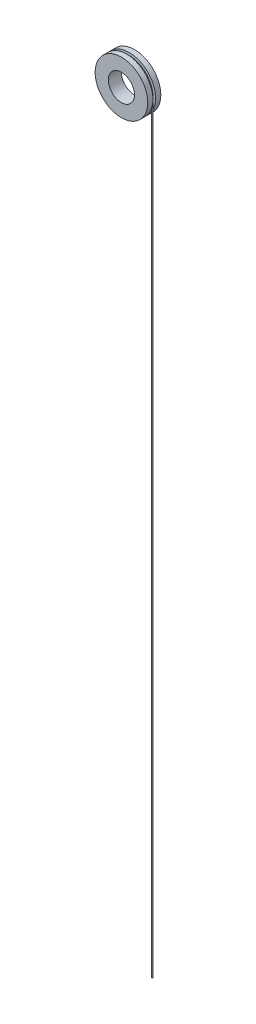
from build123d import *

# Parameters (mm, degrees)
SKETCH1_R           = 10
SKETCH1_R_2         = 5
BOSS_EXTRUDE1_DEPTH = 2.5
SKETCH2_R           = 10
SKETCH2_R_2         = 9
CUT_EXTRUDE1_DEPTH  = 0.5
SKETCH4_R           = 0.25


with BuildPart() as part:
    # Sketch1 → Boss-Extrude1 (new body, symmetric)
    with BuildSketch(Plane.XY):
        Circle(SKETCH1_R)
        Circle(SKETCH1_R_2, mode=Mode.SUBTRACT)
    extrude(amount=BOSS_EXTRUDE1_DEPTH, both=True)

    # Sketch2 → Cut-Extrude1 (cut, symmetric)
    with BuildSketch(Plane.XY):
        Circle(SKETCH2_R)
        Circle(SKETCH2_R_2, mode=Mode.SUBTRACT)
    extrude(amount=CUT_EXTRUDE1_DEPTH, both=True, mode=Mode.SUBTRACT)


with BuildPart() as body_2:
    # Sweep1: sweep along a path in Sketch3
    with BuildLine(Plane.XY) as sweep1_path:
        Line((9.25, 0), (9.25, -290))
    # Sketch4 → Sweep1 (sweep)
    with BuildSketch(Plane(origin=(0, 0, 0), x_dir=(1, 0, 0), z_dir=(0, 1, 0))):
        with Locations((9.25, 0)):
            Circle(SKETCH4_R)
    sweep(path=sweep1_path.line)


solid = Compound([part.part, body_2.part])
